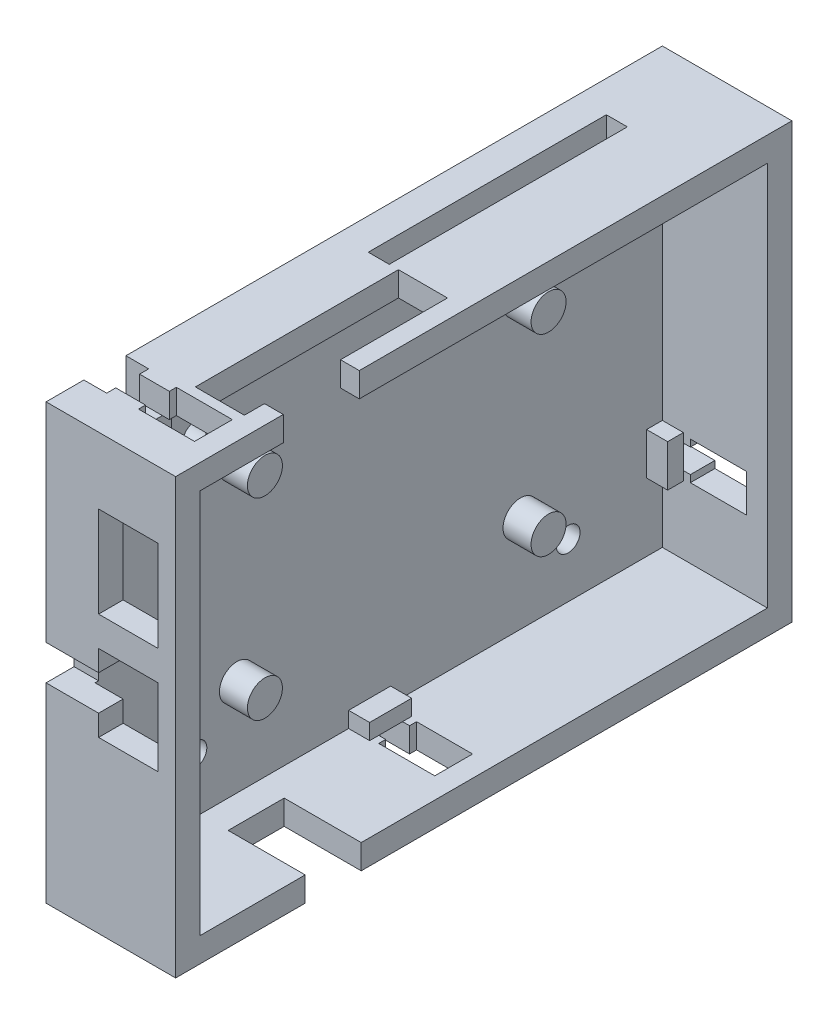
from build123d import *

# Parameters (mm, degrees)
SKETCH_1_W          = 88
SKETCH_1_H          = 62
EXTRUDE_1_DEPTH     = 3.5
SKETCH_2_W          = 88
SKETCH_2_H          = 62
SKETCH_2_W_2        = 81
SKETCH_2_H_2        = 55
EXTRUDE_2_DEPTH     = 15
SKETCH_3_R          = 2.5
EXTRUDE_3_DEPTH     = 4
SKETCH_4_W          = 3
SKETCH_4_H          = 34
SKETCH_4_W_2        = 2.683429954
SKETCH_4_H_2        = 10.857152268
CUT_EXTRUDE_2_DEPTH = 3.5
SKETCH_7_W          = 8.5
SKETCH_7_H          = 11
SKETCH_7_H_2        = 13
SKETCH_7_W_2        = 7.5
SKETCH_7_H_3        = 2.5
CUT_EXTRUDE_3_DEPTH = 4
SKETCH_8_W          = 12
SKETCH_8_H          = 8
CUT_EXTRUDE_4_DEPTH = 3.5
CUT_EXTRUDE_5_DEPTH = 3.5
SKETCH_10_R         = 1.7
CUT_EXTRUDE_6_DEPTH = 3.5
EXTRUDE_4_DEPTH     = 3
SKETCH_12_W         = 6
SKETCH_12_H         = 5.75
SKETCH_12_W_2       = 5.75
SKETCH_12_H_2       = 6
CUT_EXTRUDE_7_DEPTH = 3.25
SKETCH_13_W         = 29
SKETCH_13_H         = 3.5
EXTRUDE_5_DEPTH     = 2


with BuildPart() as part:
    # 草图1 → 凸台-拉伸1 (new body)
    with BuildSketch(Plane(origin=(0, 0, 0), x_dir=(0, 0, -1), z_dir=(1, 0, 0))):
        with Locations((40.5, 27.5)):
            Rectangle(SKETCH_1_W, SKETCH_1_H)
    extrude(amount=EXTRUDE_1_DEPTH)

    # 草图2 → 凸台-拉伸2 (add)
    with BuildSketch(Plane(origin=(3.5, 0, 0), x_dir=(0, 0, -1), z_dir=(1, 0, 0))):
        with Locations((40.5, 27.5)):
            Rectangle(SKETCH_2_W, SKETCH_2_H)
        with Locations((40.5, 27.5)):
            Rectangle(SKETCH_2_W_2, SKETCH_2_H_2, mode=Mode.SUBTRACT)
    extrude(amount=EXTRUDE_2_DEPTH)

    # 草图3 → 凸台-拉伸3 (add)
    with BuildSketch(Plane(origin=(3.5, 0, 0), x_dir=(0, 0, -1), z_dir=(1, 0, 0))):
        with Locations((20.25, 41.25)):
            Circle(SKETCH_3_R)
        with Locations((60.75, 41.25)):
            Circle(SKETCH_3_R)
        with Locations((60.75, 13.75)):
            Circle(SKETCH_3_R)
        with Locations((20.25, 13.75)):
            Circle(SKETCH_3_R)
    extrude(amount=EXTRUDE_3_DEPTH)

    # 草图4 → 切除-拉伸2 (cut)
    with BuildSketch(Plane(origin=(0, 58.5, 0), x_dir=(1, 0, 0), z_dir=(0, 1, 0))):
        with Locations((6, 55)):
            Rectangle(SKETCH_4_W, SKETCH_4_H)
        Polygon((7.5, 38), (6.816570046, 38), (6.816570046, 9), (15.816570046, 9), (15.816570046, 11.869210194), (15.816570046, 22.726362462), (15.816570046, 38), align=None)
        Polygon((0, 3.2), (7.5, 3.2), (7.5, 2.2), (15.5, 2.2), (15.5, 7.6), (7.5, 7.6), (7.5, 6.6), (0, 6.6), align=None)
        with Locations((17.158285023, 17.297786328)):
            Rectangle(SKETCH_4_W_2, SKETCH_4_H_2)
    extrude(amount=-CUT_EXTRUDE_2_DEPTH, mode=Mode.SUBTRACT)

    # 草图7 → 切除-拉伸3 (cut)
    with BuildSketch(Plane.XY.offset(3.5)):
        with Locations((11.75, 26.25)):
            Rectangle(SKETCH_7_W, SKETCH_7_H)
        with Locations((11.75, 42.5)):
            Rectangle(SKETCH_7_W, SKETCH_7_H_2)
        with Locations((3.75, 27.5)):
            Rectangle(SKETCH_7_W_2, SKETCH_7_H_3)
        with Locations((3.75, 25)):
            Rectangle(SKETCH_7_W_2, SKETCH_7_H_3)
    extrude(amount=-CUT_EXTRUDE_3_DEPTH, mode=Mode.SUBTRACT)

    # 草图8 → 切除-拉伸4 (cut)
    with BuildSketch(Plane.XZ.offset(3.5)):
        with Locations((13.5, -19)):
            Rectangle(SKETCH_8_W, SKETCH_8_H)
        Polygon((7.5, -36.5), (15.5, -36.5), (15.5, -41.9), (7.5, -41.9), (7.5, -40.9), (0, -40.9), (0, -37.5), (7.5, -37.5), align=None)
    extrude(amount=-CUT_EXTRUDE_4_DEPTH, mode=Mode.SUBTRACT)

    # 草图9 → 切除-拉伸5 (cut)
    with BuildSketch(Plane(origin=(0, 0, -84.5), x_dir=(-1, 0, 0), z_dir=(0, 0, -1))):
        Polygon((-7.5, 11), (0, 11), (0, 14.4), (-7.5, 14.4), (-7.5, 15.4), (-15.5, 15.4), (-15.5, 10), (-7.5, 10), align=None)
    extrude(amount=-CUT_EXTRUDE_5_DEPTH, mode=Mode.SUBTRACT)

    # 草图10 → 切除-拉伸6 (cut)
    with BuildSketch(Plane(origin=(3.5, 0, 0), x_dir=(0, 0, -1), z_dir=(1, 0, 0))):
        with Locations((14.25, 47.25)):
            Circle(SKETCH_10_R)
        with Locations((14.25, 7.75)):
            Circle(SKETCH_10_R)
        with Locations((67.55, 7.75)):
            Circle(SKETCH_10_R)
    extrude(amount=-CUT_EXTRUDE_6_DEPTH, mode=Mode.SUBTRACT)

    # 草图11 → 凸台-拉伸4 (add)
    with BuildSketch(Plane(origin=(3.5, 0, 0), x_dir=(0, 0, -1), z_dir=(1, 0, 0))):
        Polygon((40.9, 0), (42.2, 0), (42.2, 2.25), (36.2, 2.25), (36.2, 0), (37.5, 0), align=None)
        Polygon((81, 14.4), (81, 15.7), (78.75, 15.7), (78.75, 9.7), (81, 9.7), (81, 11), align=None)
        Polygon((4.9, 52.75), (4.9, 55), (3.2, 55), (1.9, 55), (1.9, 52.75), align=None)
        Polygon((6.6, 55), (4.9, 55), (4.9, 52.75), (7.9, 52.75), (7.9, 55), align=None)
    extrude(amount=EXTRUDE_4_DEPTH)

    # 草图12 → 切除-拉伸7 (cut)
    with BuildSketch(Plane.ZY):
        with Locations((-4.9, 55.625)):
            Rectangle(SKETCH_12_W, SKETCH_12_H)
        with Locations((-39.2, -0.625)):
            Rectangle(SKETCH_12_W, SKETCH_12_H)
        with Locations((-81.625, 12.7)):
            Rectangle(SKETCH_12_W_2, SKETCH_12_H_2)
    extrude(amount=-CUT_EXTRUDE_7_DEPTH, mode=Mode.SUBTRACT)

    # 草图13 → 凸台-拉伸5 (add)
    with BuildSketch(Plane(origin=(6.816570046, 0, 0), x_dir=(0, 0, -1), z_dir=(1, 0, 0))):
        with Locations((23.5, 56.75)):
            Rectangle(SKETCH_13_W, SKETCH_13_H)
    extrude(amount=EXTRUDE_5_DEPTH)


solid = part.part
